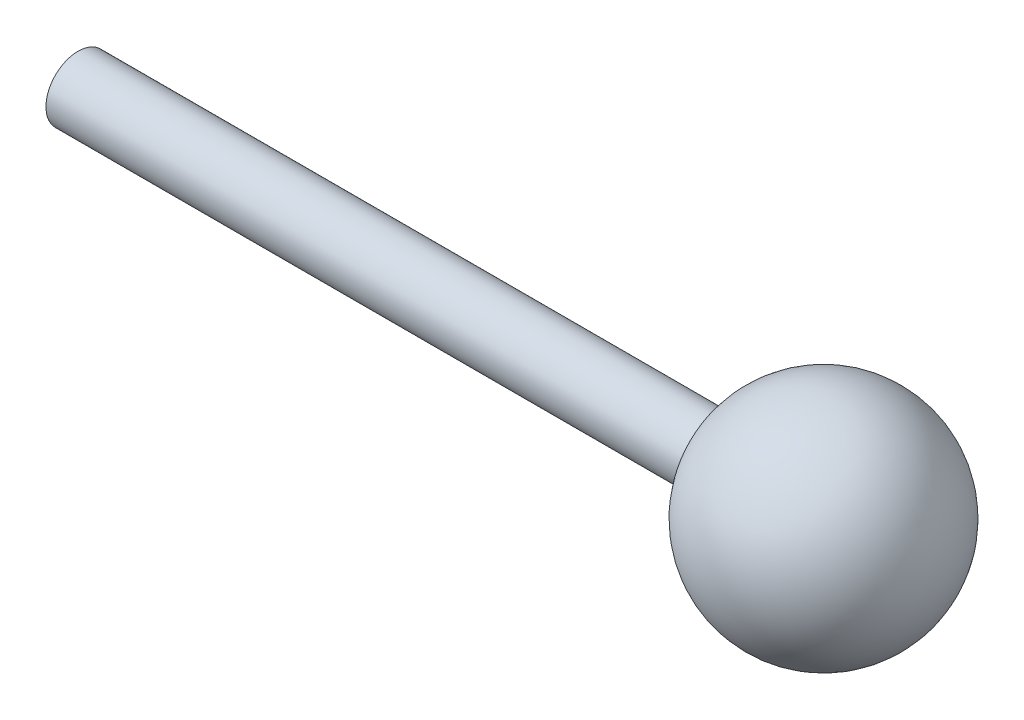
from build123d import *

# Parameters (mm, degrees)
SKETCH1_R           = 0.75
BOSS_EXTRUDE1_DEPTH = 15
DOME1_FACE_RADIUS   = 0.75
DOME1_HEIGHT        = 5


with BuildPart() as part:
    # Sketch1 → Boss-Extrude1 (new body)
    with BuildSketch(Plane(origin=(0, 0, 0), x_dir=(0, 0, -1), z_dir=(1, 0, 0))):
        with Locations((-31.784191327, 14.97266261)):
            Circle(SKETCH1_R)
    extrude(amount=BOSS_EXTRUDE1_DEPTH)

    # Dome1: a dome of height H over a round flat face of radius A is a cap of a sphere of radius (A * A + H * H) / (2 * H)
    dome1_r = (DOME1_FACE_RADIUS * DOME1_FACE_RADIUS + DOME1_HEIGHT * DOME1_HEIGHT) / (2 * DOME1_HEIGHT)
    dome1_base = Plane((15, 14.97266261, 31.784191327), z_dir=(1, 0, 0))
    with Locations(dome1_base.offset(DOME1_HEIGHT - dome1_r)):
        dome1_ball = Sphere(dome1_r, mode=Mode.PRIVATE)
    add(split(dome1_ball, bisect_by=dome1_base, keep=Keep.TOP, mode=Mode.PRIVATE))


solid = part.part
